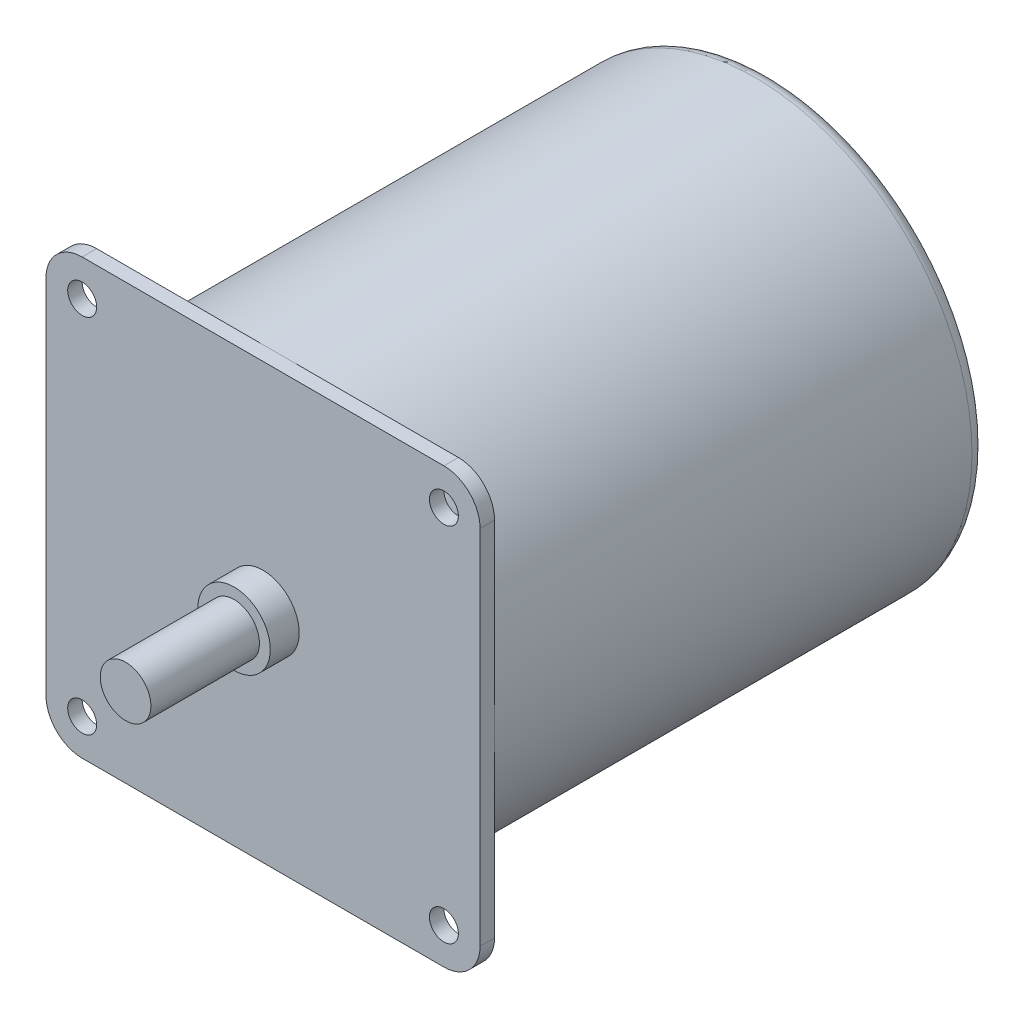
from build123d import *

# Parameters (mm, degrees)
SKETCH1_R           = 30
BOSS_EXTRUDE1_DEPTH = 68
SKETCH2_R           = 2
BOSS_EXTRUDE2_DEPTH = 2
FILLET1_R           = 2
SKETCH3_R           = 5
BOSS_EXTRUDE3_DEPTH = 4
SKETCH4_R           = 3.5
BOSS_EXTRUDE4_DEPTH = 15


with BuildPart() as part:
    # Sketch1 → Boss-Extrude1 (new body)
    with BuildSketch(Plane.XY):
        Circle(SKETCH1_R)
    extrude(amount=BOSS_EXTRUDE1_DEPTH)

    # Sketch2 → Boss-Extrude2 (add)
    with BuildSketch(Plane.XY.offset(68)):
        with BuildLine():
            Line((25, 30), (-25, 30))
            ThreePointArc((-25, 30), (-28.535533906, 28.535533906), (-30, 25))
            Line((-30, 25), (-30, -25))
            ThreePointArc((-30, -25), (-28.535533906, -28.535533906), (-25, -30))
            Line((-25, -30), (25, -30))
            ThreePointArc((25, -30), (28.535533906, -28.535533906), (30, -25))
            Line((30, -25), (30, 25))
            ThreePointArc((30, 25), (28.535533906, 28.535533906), (25, 30))
        make_face()
        with Locations((-25, 25)):
            Circle(SKETCH2_R, mode=Mode.SUBTRACT)
        with Locations((25, 25)):
            Circle(SKETCH2_R, mode=Mode.SUBTRACT)
        with Locations((25, -25)):
            Circle(SKETCH2_R, mode=Mode.SUBTRACT)
        with Locations((-25, -25)):
            Circle(SKETCH2_R, mode=Mode.SUBTRACT)
    extrude(amount=BOSS_EXTRUDE2_DEPTH)

    # Fillet1
    fillet1_edges = [part.edges().sort_by_distance(p)[0] for p in [
        (-30, 0, 0),
    ]]
    fillet(fillet1_edges, radius=FILLET1_R)

    # Sketch3 → Boss-Extrude3 (add)
    with BuildSketch(Plane.XY.offset(70)):
        Circle(SKETCH3_R)
    extrude(amount=BOSS_EXTRUDE3_DEPTH)


with BuildPart() as body_2:
    # Sketch4 → Boss-Extrude4 (new body)
    with BuildSketch(Plane.XY.offset(74)):
        Circle(SKETCH4_R)
    extrude(amount=BOSS_EXTRUDE4_DEPTH)


solid = Compound([part.part, body_2.part])
